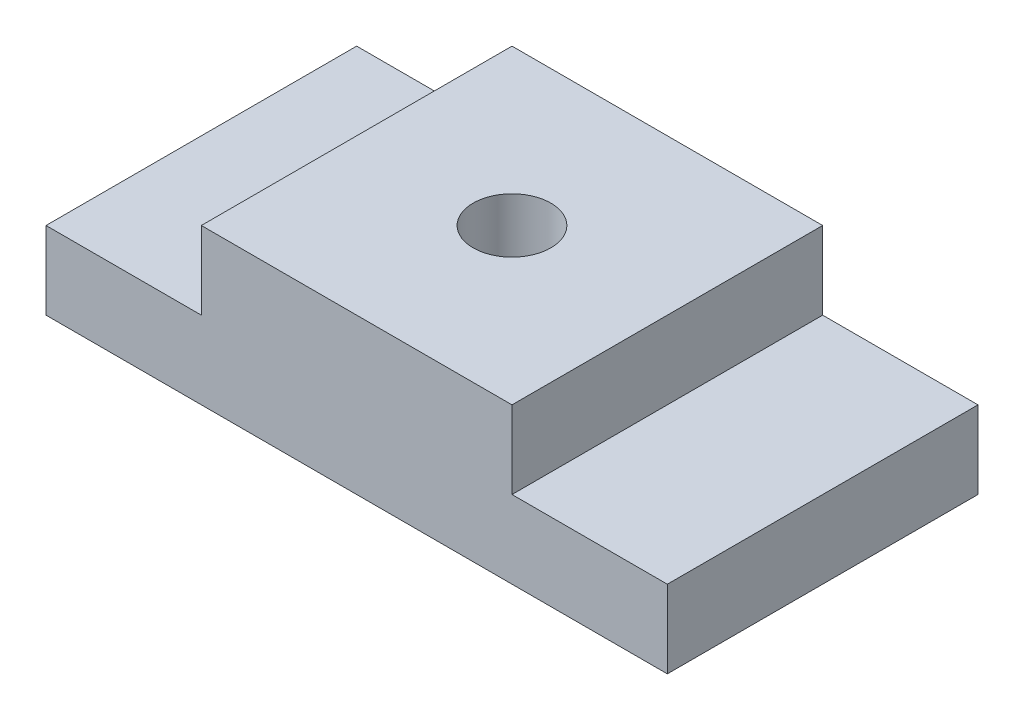
from build123d import *

# Parameters (mm, degrees)
SKETCH1_W           = 80
SKETCH1_H           = 40
BOSS_EXTRUDE1_DEPTH = 10
SKETCH2_W           = 40
SKETCH2_H           = 40
BOSS_EXTRUDE2_DEPTH = 10
SKETCH3_R           = 5
CUT_EXTRUDE1_DEPTH  = 10
SKETCH4_R           = 5
BOSS_EXTRUDE3_DEPTH = 10
SKETCH5_R           = 5
CUT_EXTRUDE2_DEPTH  = 10


with BuildPart() as part:
    # Sketch1 → Boss-Extrude1 (new body)
    with BuildSketch(Plane(origin=(0, 0, 0), x_dir=(1, 0, 0), z_dir=(0, 1, 0))):
        Rectangle(SKETCH1_W, SKETCH1_H)
    extrude(amount=BOSS_EXTRUDE1_DEPTH)

    # Sketch2 → Boss-Extrude2 (add)
    with BuildSketch(Plane(origin=(0, 10, 0), x_dir=(1, 0, 0), z_dir=(0, 1, 0))):
        Rectangle(SKETCH2_W, SKETCH2_H)
    extrude(amount=BOSS_EXTRUDE2_DEPTH)

    # Sketch3 → Cut-Extrude1 (cut)
    with BuildSketch(Plane(origin=(0, 20, 0), x_dir=(1, 0, 0), z_dir=(0, 1, 0))):
        Circle(SKETCH3_R)
    extrude(amount=-CUT_EXTRUDE1_DEPTH, mode=Mode.SUBTRACT)

    # Sketch4 → Boss-Extrude3 (add)
    with BuildSketch(Plane(origin=(0, 10, 0), x_dir=(1, 0, 0), z_dir=(0, 1, 0))):
        Circle(SKETCH4_R)
    extrude(amount=BOSS_EXTRUDE3_DEPTH)

    # Sketch5 → Cut-Extrude2 (cut)
    with BuildSketch(Plane(origin=(0, 20, 0), x_dir=(1, 0, 0), z_dir=(0, 1, 0))):
        Circle(SKETCH5_R)
    extrude(amount=-CUT_EXTRUDE2_DEPTH, mode=Mode.SUBTRACT)


solid = part.part
